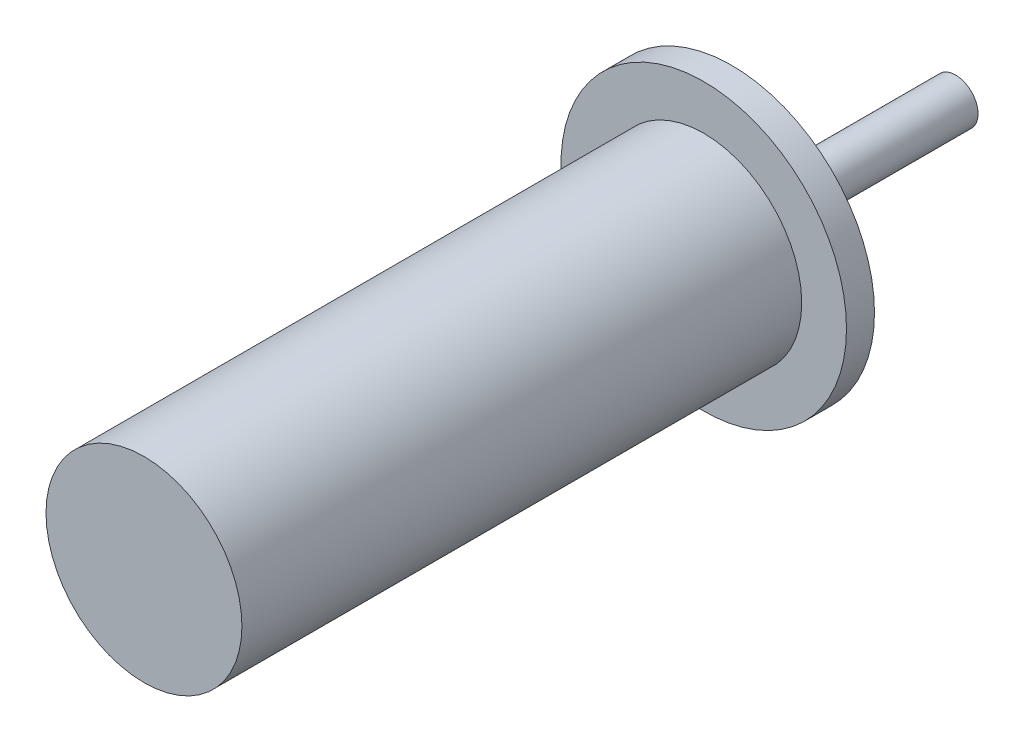
from build123d import *

# Parameters (mm, degrees)
SKETCH1_R           = 25.5
BOSS_EXTRUDE3_DEPTH = 5
SKETCH3_R           = 17.5
BOSS_EXTRUDE4_DEPTH = 100
SKETCH4_R           = 4
BOSS_EXTRUDE5_DEPTH = 40


with BuildPart() as part:
    # Sketch1 → Boss-Extrude3 (new body)
    with BuildSketch(Plane.XY):
        Circle(SKETCH1_R)
    extrude(amount=BOSS_EXTRUDE3_DEPTH)

    # Sketch3 → Boss-Extrude4 (add)
    with BuildSketch(Plane.XY.offset(5)):
        Circle(SKETCH3_R)
    extrude(amount=BOSS_EXTRUDE4_DEPTH)

    # Sketch4 → Boss-Extrude5 (add)
    with BuildSketch(Plane(origin=(0, 0, 0), x_dir=(-1, 0, 0), z_dir=(0, 0, -1))):
        Circle(SKETCH4_R)
    extrude(amount=BOSS_EXTRUDE5_DEPTH)


solid = part.part
